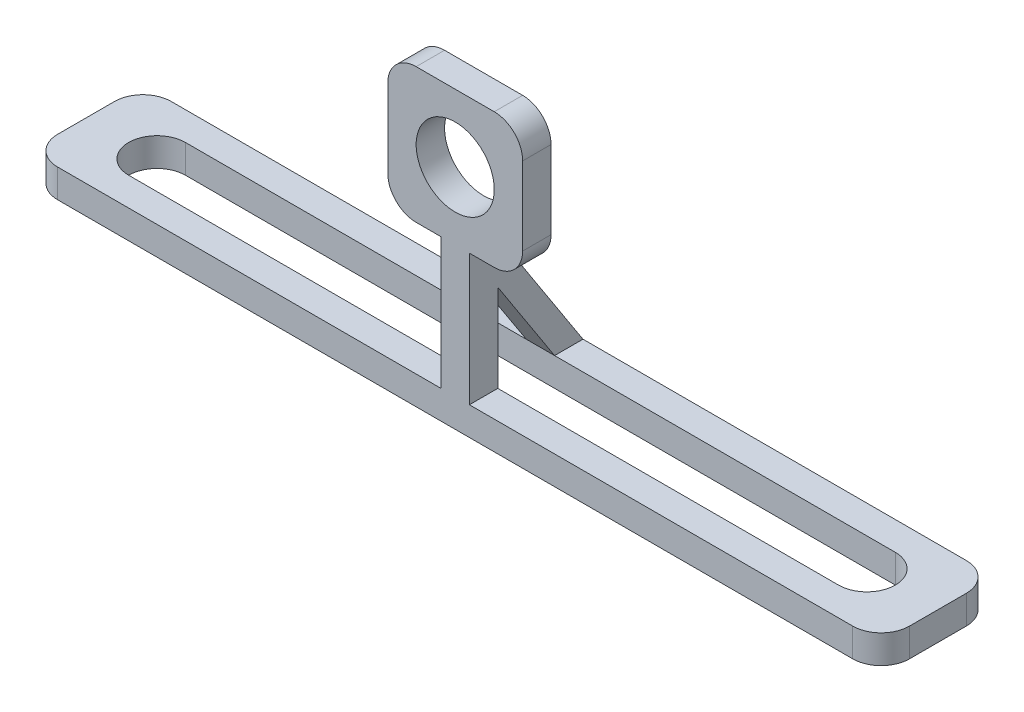
from build123d import *

# Parameters (mm, degrees)
BOSS_EXTRUDE1_DEPTH = 20.75
SKETCH2_R           = 2.75
CUT_EXTRUDE1_DEPTH  = 20.75
SKETCH3_W           = 2
SKETCH3_H           = 18.75
CUT_EXTRUDE2_DEPTH  = 20.75
FILLET1_R           = 2
BOSS_EXTRUDE2_DEPTH = 2


with BuildPart() as part:
    # Sketch1 → Boss-Extrude1 (new body)
    with BuildSketch(Plane(origin=(0, 0, 0), x_dir=(1, 0, 0), z_dir=(0, 1, 0))):
        with BuildLine():
            Line((-30, 0), (0, 0))
            Line((0, 0), (30, 0))
            Line((30, 0), (30, 4))
            Line((30, 4), (27, 4))
            ThreePointArc((27, 4), (26.414213562, 2.585786438), (25, 2))
            Line((25, 2), (-25, 2))
            ThreePointArc((-25, 2), (-26.414213562, 2.585786438), (-27, 4))
            Line((-27, 4), (-30, 4))
            Line((-30, 4), (-30, 0))
        make_face()
        with BuildLine():
            Line((27, 4), (30, 4))
            Line((30, 4), (30, 8))
            Line((30, 8), (-30, 8))
            Line((-30, 8), (-30, 4))
            Line((-30, 4), (-27, 4))
            ThreePointArc((-27, 4), (-26.414213562, 5.414213562), (-25, 6))
            Line((-25, 6), (25, 6))
            ThreePointArc((25, 6), (26.414213562, 5.414213562), (27, 4))
        make_face()
    extrude(amount=BOSS_EXTRUDE1_DEPTH)

    # Sketch2 → Cut-Extrude1 (cut)
    with BuildSketch(Plane.XY):
        Polygon((-30, 20.75), (-30, 2), (-1, 2), (-1, 11.25), (-4.75, 11.25), (-4.75, 20.75), align=None)
        with Locations((0, 16)):
            Circle(SKETCH2_R)
        Polygon((4.75, 11.25), (1, 11.25), (1, 2), (30, 2), (30, 20.75), (4.75, 20.75), align=None)
    extrude(amount=-CUT_EXTRUDE1_DEPTH, mode=Mode.SUBTRACT)

    # Sketch3 → Cut-Extrude2 (cut)
    with BuildSketch(Plane(origin=(4.75, 0, 0), x_dir=(0, 0, -1), z_dir=(1, 0, 0))):
        with Locations((7, 11.375)):
            Rectangle(SKETCH3_W, SKETCH3_H)
    extrude(amount=-CUT_EXTRUDE2_DEPTH, mode=Mode.SUBTRACT)

    # Fillet1
    fillet1_edges = [part.edges().sort_by_distance(p)[0] for p in [
        (4.75, 20.75, -1),
        (-4.75, 20.75, -1),
        (30, 1, -8),
        (30, 1, 0),
        (-30, 1, 0),
        (-30, 1, -8),
        (-4.75, 11.25, -1),
        (4.75, 11.25, -1),
    ]]
    fillet(fillet1_edges, radius=FILLET1_R)

    # Sketch5 → Boss-Extrude2 (add)
    with BuildSketch(Plane(origin=(1, 0, 0), x_dir=(0, 0, -1), z_dir=(1, 0, 0))):
        Polygon((2, 11.25), (8, 2), (6, 2), (2, 8.166666667), align=None)
    extrude(amount=-BOSS_EXTRUDE2_DEPTH)


solid = part.part
